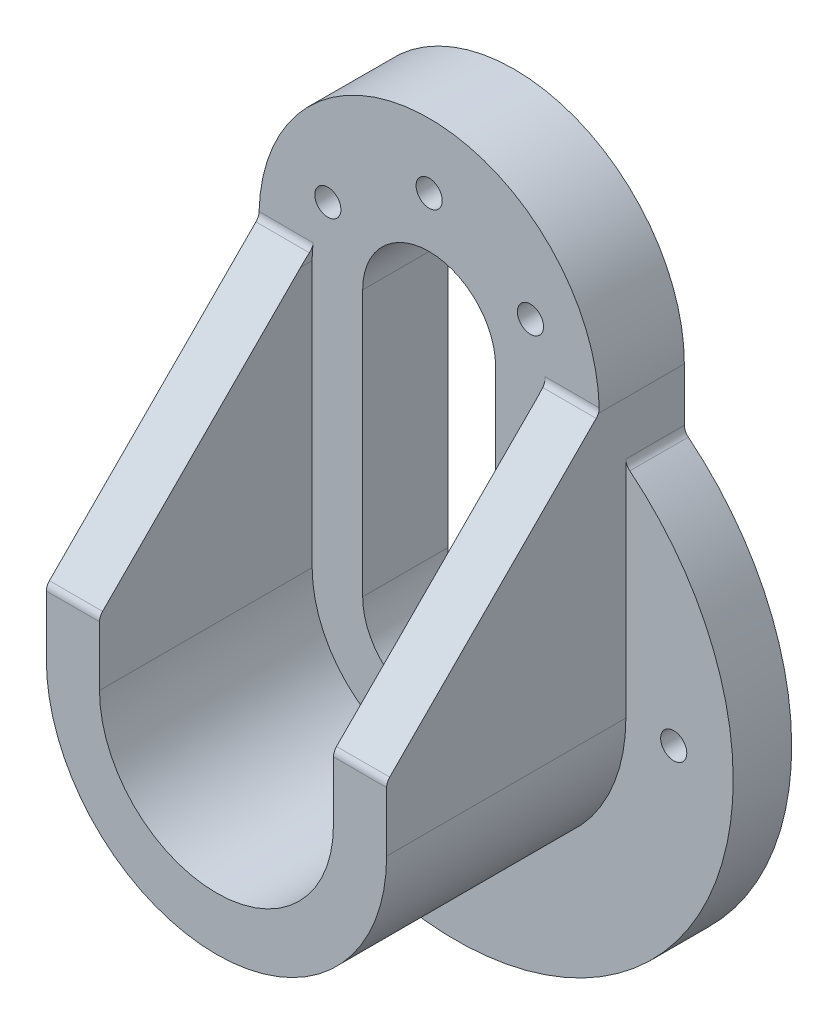
from build123d import *

# Parameters (mm, degrees)
BOSS_EXTRUDE1_DEPTH          = 40
BOSS_EXTRUDE1_DEPTH_BACK     = 16
BOSS_EXTRUDE2_START          = -5
SKETCH1_3_R                  = 52.187837327
BOSS_EXTRUDE2_DEPTH          = 11
CUT_EXTRUDE1_DEPTH           = 114.785598028
CUT_EXTRUDE3_DEPTH           = 40
CUT_EXTRUDE4_DEPTH           = 126.599298993
FILLET1_R                    = 2
F_10_0_1935_DIAMETER_HOLE3_D = 4.9149
F_10_0_1935_DIAMETER_HOLE4_D = 4.9149
FILLET2_R                    = 2
FILLET3_R                    = 2


with BuildPart() as part:
    # Sketch1 → Boss-Extrude1 (new, two sides: drawn at the far end of the back side and taken through both)
    with BuildSketch(Plane.XY.offset(-BOSS_EXTRUDE1_DEPTH_BACK)):
        with BuildLine():
            ThreePointArc((-32, 0), (0, -32), (32, 0))
            Line((32, 0), (32, 52.187837327))
            ThreePointArc((32, 52.187837327), (0, 84.187837327), (-32, 52.187837327))
            Line((-32, 52.187837327), (-32, 0))
        make_face()
    extrude(amount=BOSS_EXTRUDE1_DEPTH + BOSS_EXTRUDE1_DEPTH_BACK)

    # Sketch1_3 → Boss-Extrude2 (add)
    with BuildSketch(Plane.XY.offset(BOSS_EXTRUDE2_START)):
        Circle(SKETCH1_3_R)
    extrude(amount=-BOSS_EXTRUDE2_DEPTH)

    # Sketch2 → Cut-Extrude1 (cut, through all)
    with BuildSketch(Plane.XY.offset(40)):
        with BuildLine():
            Line((-12.5, 0), (-12.5, 50))
            ThreePointArc((-12.5, 50), (0, 62.5), (12.5, 50))
            Line((12.5, 50), (12.5, 0))
            ThreePointArc((12.5, 0), (0, -12.5), (-12.5, 0))
        make_face()
    extrude(amount=-CUT_EXTRUDE1_DEPTH, mode=Mode.SUBTRACT)

    # Sketch6 → Cut-Extrude3 (cut)
    with BuildSketch(Plane.XY.offset(40)):
        with BuildLine():
            Line((-22, 0), (-22, 50))
            ThreePointArc((-22, 50), (0, 72), (22, 50))
            Line((22, 50), (22, 0))
            ThreePointArc((22, 0), (0, -22), (-22, 0))
        make_face()
    extrude(amount=-CUT_EXTRUDE3_DEPTH, mode=Mode.SUBTRACT)

    # Sketch7 → Cut-Extrude4 (cut, through all)
    with BuildSketch(Plane(origin=(32, 0, 0), x_dir=(0, 0, -1), z_dir=(1, 0, 0))):
        Polygon((0, 52.187837327), (0, 84.187837327), (-40, 84.187837327), (-40, 12), align=None)
    extrude(amount=-CUT_EXTRUDE4_DEPTH, mode=Mode.SUBTRACT)

    # Fillet1
    fillet1_edges = [part.edges().sort_by_distance(p)[0] for p in [
        (27, 12, 40),
        (-27, 12, 40),
    ]]
    fillet(fillet1_edges, radius=FILLET1_R)

    # 10 _0.1935_ Diameter Hole3 (through all)
    with Locations(Plane.XY):
        with Locations((-19.052558883, 61), (19.052558883, 61), (0, 72)):
            Hole(F_10_0_1935_DIAMETER_HOLE3_D / 2)

    # 10 _0.1935_ Diameter Hole4 (through all)
    with Locations(Plane(origin=(0, 0, -16), x_dir=(-1, 0, 0), z_dir=(0, 0, -1))):
        with Locations((0, -41), (41, 0), (-41, 0)):
            Hole(F_10_0_1935_DIAMETER_HOLE4_D / 2)

    # Fillet2
    fillet2_edges = [part.edges().sort_by_distance(p)[0] for p in [
        (26.945471299, 52.187837327, 0),
        (-26.945471299, 52.187837327, 0),
    ]]
    fillet(fillet2_edges, radius=FILLET2_R)

    # Fillet3
    fillet3_edges = [part.edges().sort_by_distance(p)[0] for p in [
        (-32, 41.225845835, -10.5),
        (32, 41.225845835, -10.5),
    ]]
    fillet(fillet3_edges, radius=FILLET3_R)


solid = part.part
